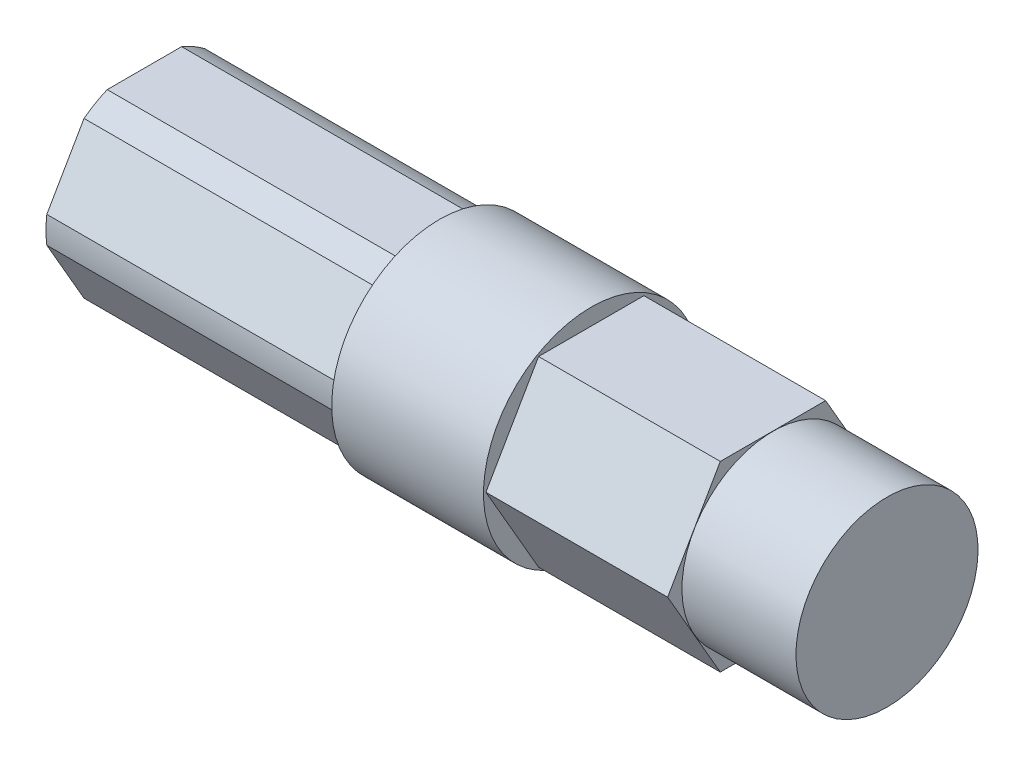
from build123d import *

# Parameters (mm, degrees)
SKETCH1_W                       = 10.5664
SKETCH1_H                       = 7.5
BOSS_EXTRUDE1_DEPTH             = 20.5359
BOSS_EXTRUDE2_DEPTH             = 12.6492
SKETCH4_W                       = 7.9375
SKETCH4_H                       = 6.3373
F_21_0_159_DIAMETER_HOLE1_D     = 4.0386
F_21_0_159_DIAMETER_HOLE1_DEPTH = 15.875
F_21_0_159_DIAMETER_HOLE1_TIP   = 1.213317848
SKETCH7_R                       = 3.175
CUT_EXTRUDE1_DEPTH              = 12.7


with BuildPart() as part:
    # Sketch1 → Revolve1 (revolve)
    with BuildSketch(Plane.XY):
        with Locations((3.94335, 3.75)):
            Rectangle(SKETCH1_W, SKETCH1_H)
    revolve(axis=Axis((-1.33985, 0, 0), (1, 0, 0)))

    # Sketch2 → Boss-Extrude1 (add)
    with BuildSketch(Plane.ZY.offset(1.33985)):
        with BuildLine():
            Line((-2.590301913, 6.35), (2.590301913, 6.35))
            ThreePointArc((2.590301913, 6.35), (3.429, 5.939202219), (4.204110358, 5.41826726))
            Line((4.204110358, 5.41826726), (6.79441227, 0.93173274))
            ThreePointArc((6.79441227, 0.93173274), (6.858, 0), (6.79441227, -0.93173274))
            Line((6.79441227, -0.93173274), (4.204110358, -5.41826726))
            ThreePointArc((4.204110358, -5.41826726), (3.429, -5.939202219), (2.590301913, -6.35))
            Line((2.590301913, -6.35), (-2.590301913, -6.35))
            ThreePointArc((-2.590301913, -6.35), (-3.429, -5.939202219), (-4.204110358, -5.41826726))
            Line((-4.204110358, -5.41826726), (-6.79441227, -0.93173274))
            ThreePointArc((-6.79441227, -0.93173274), (-6.858, 0), (-6.79441227, 0.93173274))
            Line((-6.79441227, 0.93173274), (-4.204110358, 5.41826726))
            ThreePointArc((-4.204110358, 5.41826726), (-3.429, 5.939202219), (-2.590301913, 6.35))
        make_face()
    extrude(amount=BOSS_EXTRUDE1_DEPTH)

    # Sketch3 → Boss-Extrude2 (add)
    with BuildSketch(Plane(origin=(9.22655, 0, 0), x_dir=(0, 0, -1), z_dir=(1, 0, 0))):
        Polygon((3.666174209, -6.35), (-3.666174209, -6.35), (-7.332348419, 0), (-3.666174209, 6.35), (3.666174209, 6.35), (7.332348419, 0), align=None)
    extrude(amount=BOSS_EXTRUDE2_DEPTH)

    # Sketch4 → Revolve2 (revolve)
    with BuildSketch(Plane(origin=(0, 0, 0), x_dir=(-1, 0, 0), z_dir=(0, 0, -1))):
        with Locations((-25.8445, 3.16865)):
            Rectangle(SKETCH4_W, SKETCH4_H)
    revolve(axis=Axis((29.81325, 0, 0), (-1, 0, 0)))

    # #21 (0.159) Diameter Hole1
    with Locations(Plane.ZY.offset(21.87575)):
        with Locations((0, 0)):
            Hole(F_21_0_159_DIAMETER_HOLE1_D / 2, depth=F_21_0_159_DIAMETER_HOLE1_DEPTH)
            with Locations((0, 0, -(F_21_0_159_DIAMETER_HOLE1_DEPTH + F_21_0_159_DIAMETER_HOLE1_TIP / 2))):  # 118° drill point
                Cone(0, F_21_0_159_DIAMETER_HOLE1_D / 2, F_21_0_159_DIAMETER_HOLE1_TIP, mode=Mode.SUBTRACT)

    # Sketch7 → Cut-Extrude1 (cut)
    with BuildSketch(Plane.ZY.offset(21.87575)):
        Circle(SKETCH7_R)
    extrude(amount=-CUT_EXTRUDE1_DEPTH, mode=Mode.SUBTRACT)


solid = part.part
